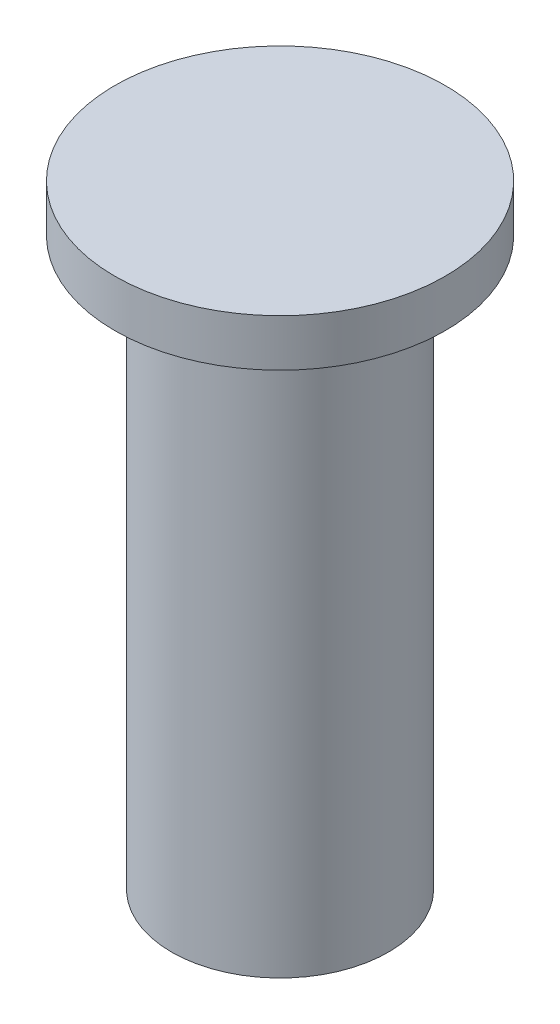
from build123d import *

# Parameters (mm, degrees)
SKETCH1_R       = 2.3
MAIN_BODY_DEPTH = 12
SKETCH2_R       = 3.5
PIN_HEAD_DEPTH  = 1


with BuildPart() as part:
    # Sketch1 → main_body (new body)
    with BuildSketch(Plane(origin=(0, 0, 0), x_dir=(1, 0, 0), z_dir=(0, 1, 0))):
        Circle(SKETCH1_R)
    extrude(amount=MAIN_BODY_DEPTH)

    # Sketch2 → pin_head (add)
    with BuildSketch(Plane(origin=(0, 12, 0), x_dir=(1, 0, 0), z_dir=(0, 1, 0))):
        Circle(SKETCH2_R)
    extrude(amount=PIN_HEAD_DEPTH)


solid = part.part
